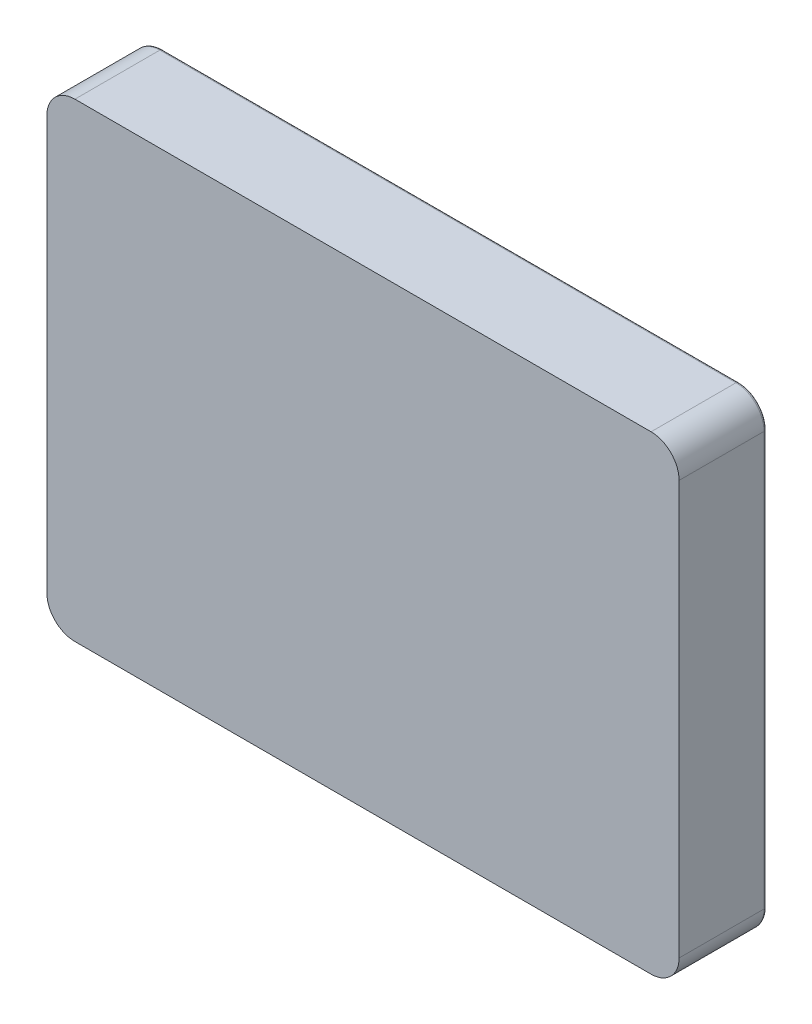
from build123d import *

# Parameters (mm, degrees)
BOSS_EXTRU_2_DEPTH      = 31.242
ESQUISSE1_6_W           = 205.926380568
ESQUISSE1_6_H           = 152.99378218
ENL_V_MAT_EXTRU_3_DEPTH = 1
CONG_2_R                = 1


with BuildPart() as part:
    # Esquisse1 → Boss.-Extru.2 (new body)
    with BuildSketch(Plane.XY):
        with BuildLine():
            Line((-102.649, -83.693), (102.649, -83.693))
            ThreePointArc((102.649, -83.693), (109.720067812, -80.764067812), (112.649, -73.693))
            Line((112.649, -73.693), (112.649, 73.693))
            ThreePointArc((112.649, 73.693), (109.720067812, 80.764067812), (102.649, 83.693))
            Line((102.649, 83.693), (-102.649, 83.693))
            ThreePointArc((-102.649, 83.693), (-109.720067812, 80.764067812), (-112.649, 73.693))
            Line((-112.649, 73.693), (-112.649, -73.693))
            ThreePointArc((-112.649, -73.693), (-109.720067812, -80.764067812), (-102.649, -83.693))
        make_face()
    extrude(amount=BOSS_EXTRU_2_DEPTH)

    # Esquisse1_6 → Enl_v. mat.-Extru.3 (cut)
    with BuildSketch(Plane.XY):
        Rectangle(ESQUISSE1_6_W, ESQUISSE1_6_H)
    extrude(amount=ENL_V_MAT_EXTRU_3_DEPTH, mode=Mode.SUBTRACT)

    # Cong_2
    cong_2_edges = [part.edges().sort_by_distance(p)[0] for p in [
        (-109.720067812, 80.764067812, 0),
        (-112.649, 0, 0),
        (-109.720067812, -80.764067812, 0),
        (0, -83.693, 0),
        (109.720067812, -80.764067812, 0),
        (112.649, 0, 0),
        (109.720067812, 80.764067812, 0),
        (0, 83.693, 0),
    ]]
    fillet(cong_2_edges, radius=CONG_2_R)


solid = part.part
